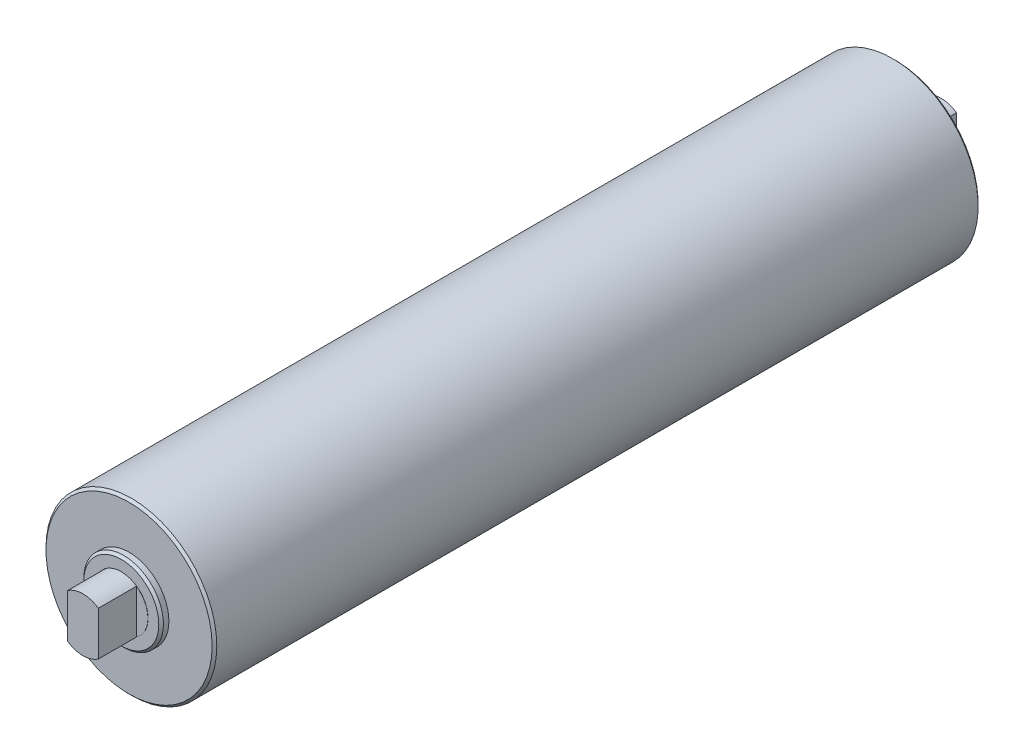
from build123d import *

# Parameters (mm, degrees)
SKETCH1_R                = 55.753
EXTRUDE1_DEPTH           = 250.063
SKETCH2_R                = 26
EXTRUDE2_DEPTH           = 5.08
SKETCH3_R                = 17.5
EXTRUDE3_DEPTH           = 25.019
SKETCH4_W                = 7.467
SKETCH4_H                = 28.676743958
CUT_EXTRUDE1_DEPTH       = 24.892
CHAMFER1_SIZE            = 1.524
CHAMFER1_OF_MIRROR1_SIZE = 1.524


with BuildPart() as part:
    # Sketch1 → Extrude1 (new body)
    with BuildSketch(Plane.XY):
        Circle(SKETCH1_R)
    extrude1 = extrude(amount=EXTRUDE1_DEPTH)

    # Sketch2 → Extrude2 (add)
    with BuildSketch(Plane.XY.offset(250.063)):
        Circle(SKETCH2_R)
    extrude2 = extrude(amount=EXTRUDE2_DEPTH)

    # Sketch3 → Extrude3 (add)
    with BuildSketch(Plane.XY.offset(255.143)):
        Circle(SKETCH3_R)
    extrude3 = extrude(amount=EXTRUDE3_DEPTH)

    # Sketch4 → Cut-Extrude1 (cut)
    with BuildSketch(Plane.XY.offset(280.162)):
        with Locations((13.7665, 0)):
            Rectangle(SKETCH4_W, SKETCH4_H)
        with Locations((-13.7665, 0)):
            Rectangle(SKETCH4_W, SKETCH4_H)
    cut_extrude1 = extrude(amount=-CUT_EXTRUDE1_DEPTH, mode=Mode.SUBTRACT)

    # Chamfer1
    chamfer1_edges = [part.edges().sort_by_distance(p)[0] for p in [
        (-55.753, 0, 250.063),
        (-26, 0, 255.143),
    ]]
    chamfer(chamfer1_edges, length=CHAMFER1_SIZE)

    # Mirror1: Extrude1, Extrude2, Extrude3, Cut-Extrude1 across plane
    add(extrude1.mirror(Plane.XY))
    add(extrude2.mirror(Plane.XY))
    add(extrude3.mirror(Plane.XY))
    add(cut_extrude1.mirror(Plane.XY), mode=Mode.SUBTRACT)

    # Chamfer1 of Mirror1
    chamfer1_of_mirror1_edges = [part.edges().sort_by_distance(p)[0] for p in [
        (-55.753, 0, -250.063),
        (-26, 0, -255.143),
    ]]
    chamfer(chamfer1_of_mirror1_edges, length=CHAMFER1_OF_MIRROR1_SIZE)


solid = part.part
